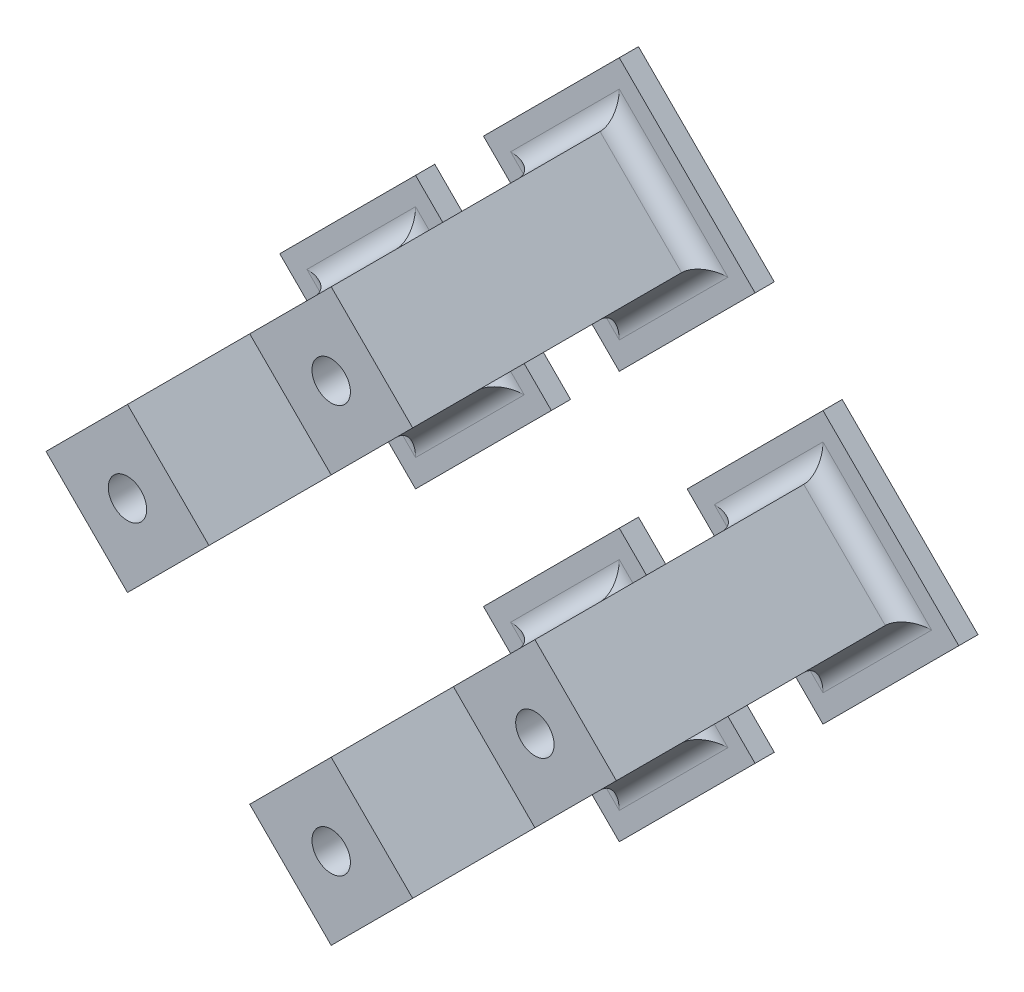
from build123d import *

# Parameters (mm, degrees)
BASE_DEPTH          = 1
BOSS_EXTRUDE2_DEPTH = 15
SKETCH3_R           = 1
CUT_EXTRUDE1_DEPTH  = 17
FILLET1_R           = 1
SKETCH4_R           = 3
CUT_EXTRUDE2_DEPTH  = 1
LPATTERN1_COUNT     = 2
LPATTERN1_PITCH     = 15
LPATTERN1_2_COUNT   = 2
LPATTERN1_2_PITCH   = 15


with BuildPart() as part:
    # Sketch1 → Base (new body)
    with BuildSketch(Plane.XY):
        Polygon((-7.071067812, 0), (0, 7.071067812), (7.071067812, 0), (0, -7.071067812), align=None)
    extrude(amount=BASE_DEPTH)

    # Sketch2 → Boss-Extrude2 (add)
    with BuildSketch(Plane.XY.offset(1)):
        Polygon((0, -4.242640687), (4.242640687, 0), (0, 4.242640687), (-4.242640687, 0), align=None)
    extrude(amount=BOSS_EXTRUDE2_DEPTH)

    # Sketch3 → Cut-Extrude1 (cut, through all)
    with BuildSketch(Plane.XY.offset(16)):
        Circle(SKETCH3_R)
    extrude(amount=-CUT_EXTRUDE1_DEPTH, mode=Mode.SUBTRACT)

    # Fillet1
    fillet1_edges = [part.edges().sort_by_distance(p)[0] for p in [
        (-2.121320344, -2.121320344, 1),
        (2.121320344, -2.121320344, 1),
        (2.121320344, 2.121320344, 1),
        (-2.121320344, 2.121320344, 1),
    ]]
    fillet(fillet1_edges, radius=FILLET1_R)

    # Sketch4 → Cut-Extrude2 (cut)
    with BuildSketch(Plane(origin=(0, 0, 0), x_dir=(-1, 0, 0), z_dir=(0, 0, -1))):
        Circle(SKETCH4_R)
    extrude(amount=-CUT_EXTRUDE2_DEPTH, mode=Mode.SUBTRACT)


with BuildPart() as lpattern1_1:
    # LPattern1: pattern copy
    add(part.part.moved(Location(Vector(-0.707106781, 0.707106781, 0) * (1 * LPATTERN1_PITCH))))


with BuildPart() as lpattern1_2_1:
    # LPattern1 2: pattern copy
    add(part.part.moved(Location(Vector(-0.707106781, -0.707106781, 0) * (1 * LPATTERN1_2_PITCH))))


with BuildPart() as lpattern1_2_2:
    # LPattern1 2: pattern copy
    add(lpattern1_1.part.moved(Location(Vector(-0.707106781, -0.707106781, 0) * (1 * LPATTERN1_2_PITCH))))


solid = Compound([part.part, lpattern1_1.part, lpattern1_2_1.part, lpattern1_2_2.part])
